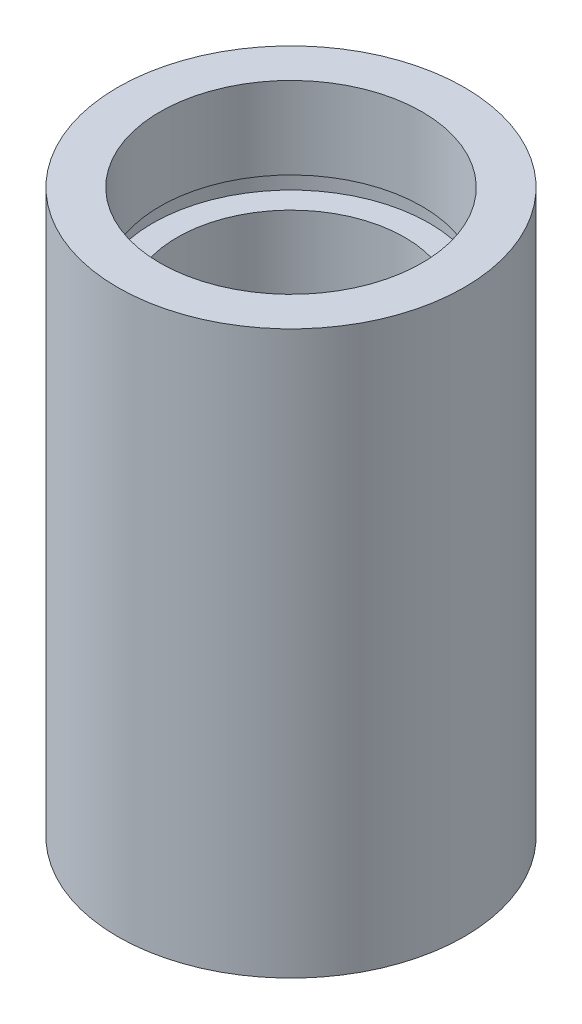
from build123d import *


with BuildPart() as part:
    # 草图1 → 旋转1 (revolve)
    with BuildSketch(Plane.XY, mode=Mode.PRIVATE) as revolve_1_sk:
        Polygon((7, 0), (7, 4.5), (7.6, 4.5), (7.6, 5.5), (6.25, 5.5), (6.25, 25.4), (7.6, 25.4), (7.6, 26.4), (7.2, 26.4), (7.2, 30.9), (9.525, 30.9), (9.525, 0), align=None)
    revolve(revolve_1_sk.sketch.rotate(Axis((0, 161.376166943, 0), (0, -1, 0)), 90), axis=Axis((0, 161.376166943, 0), (0, -1, 0)))  # turned: the seam where the file's is


solid = part.part
